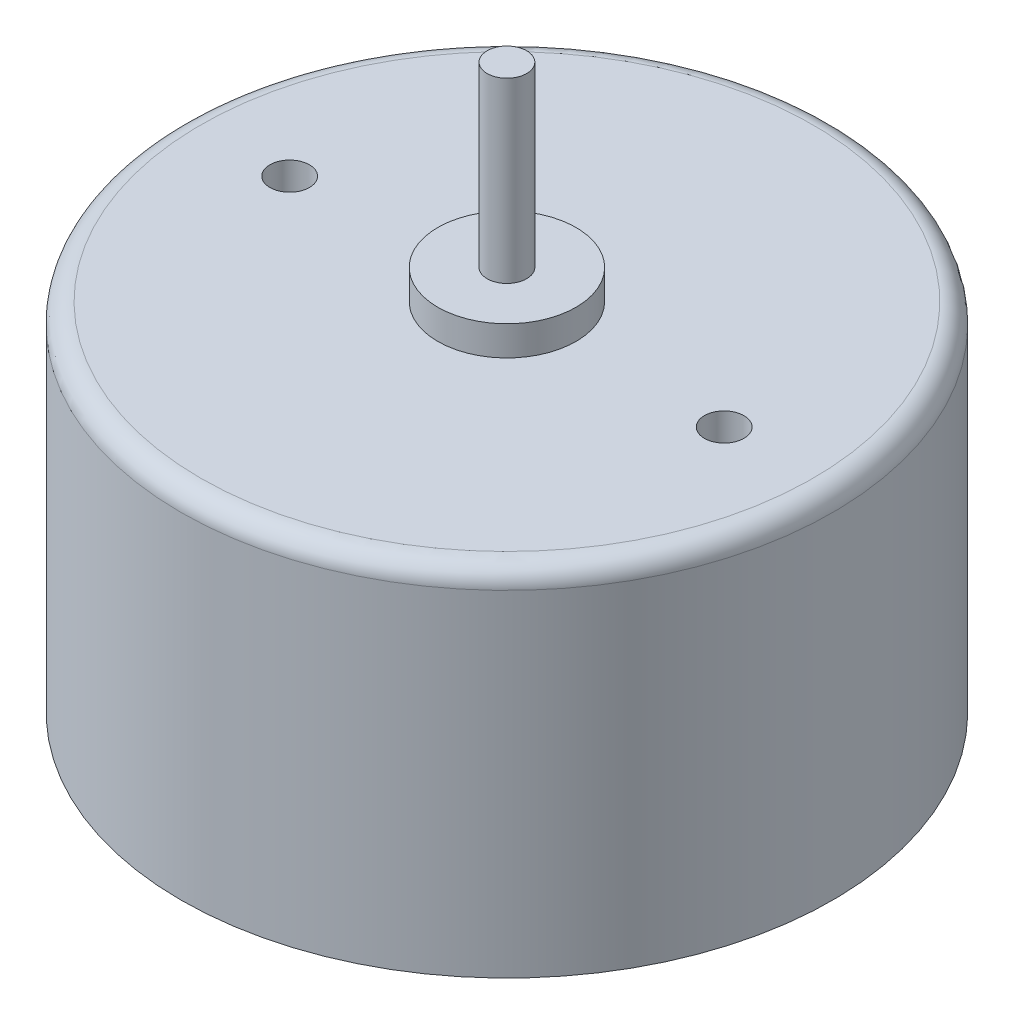
from build123d import *

# Parameters (mm, degrees)
SKETCH1_R           = 16.5
BOSS_EXTRUDE1_DEPTH = 18
SKETCH2_R           = 3.5
BOSS_EXTRUDE2_DEPTH = 1.5
SKETCH3_R           = 1
BOSS_EXTRUDE3_DEPTH = 9
FILLET1_R           = 1
SKETCH4_R           = 1
CUT_EXTRUDE1_DEPTH  = 1.5
SKETCH5_R           = 3.5
BOSS_EXTRUDE4_DEPTH = 3
SKETCH6_R           = 15.8
SKETCH6_R_2         = 3.5
CUT_EXTRUDE2_DEPTH  = 0.5


with BuildPart() as part:
    # Sketch1 → Boss-Extrude1 (new body)
    with BuildSketch(Plane(origin=(0, 0, 0), x_dir=(1, 0, 0), z_dir=(0, 1, 0))):
        Circle(SKETCH1_R)
    extrude(amount=BOSS_EXTRUDE1_DEPTH)

    # Sketch2 → Boss-Extrude2 (add)
    with BuildSketch(Plane(origin=(0, 18, 0), x_dir=(1, 0, 0), z_dir=(0, 1, 0))):
        Circle(SKETCH2_R)
    extrude(amount=BOSS_EXTRUDE2_DEPTH)

    # Sketch3 → Boss-Extrude3 (add)
    with BuildSketch(Plane(origin=(0, 19.5, 0), x_dir=(1, 0, 0), z_dir=(0, 1, 0))):
        Circle(SKETCH3_R)
    extrude(amount=BOSS_EXTRUDE3_DEPTH)

    # Fillet1
    fillet1_edges = [part.edges().sort_by_distance(p)[0] for p in [
        (-16.5, 18, 0),
    ]]
    fillet(fillet1_edges, radius=FILLET1_R)

    # Sketch4 → Cut-Extrude1 (cut)
    with BuildSketch(Plane(origin=(0, 18, 0), x_dir=(1, 0, 0), z_dir=(0, 1, 0))):
        with Locations((11, 0)):
            Circle(SKETCH4_R)
        with Locations((-11, 0)):
            Circle(SKETCH4_R)
    extrude(amount=-CUT_EXTRUDE1_DEPTH, mode=Mode.SUBTRACT)

    # Sketch5 → Boss-Extrude4 (add)
    with BuildSketch(Plane.XZ):
        Circle(SKETCH5_R)
    extrude(amount=BOSS_EXTRUDE4_DEPTH)

    # Sketch6 → Cut-Extrude2 (cut)
    with BuildSketch(Plane.XZ):
        Circle(SKETCH6_R)
        Circle(SKETCH6_R_2, mode=Mode.SUBTRACT)
    extrude(amount=-CUT_EXTRUDE2_DEPTH, mode=Mode.SUBTRACT)


solid = part.part
